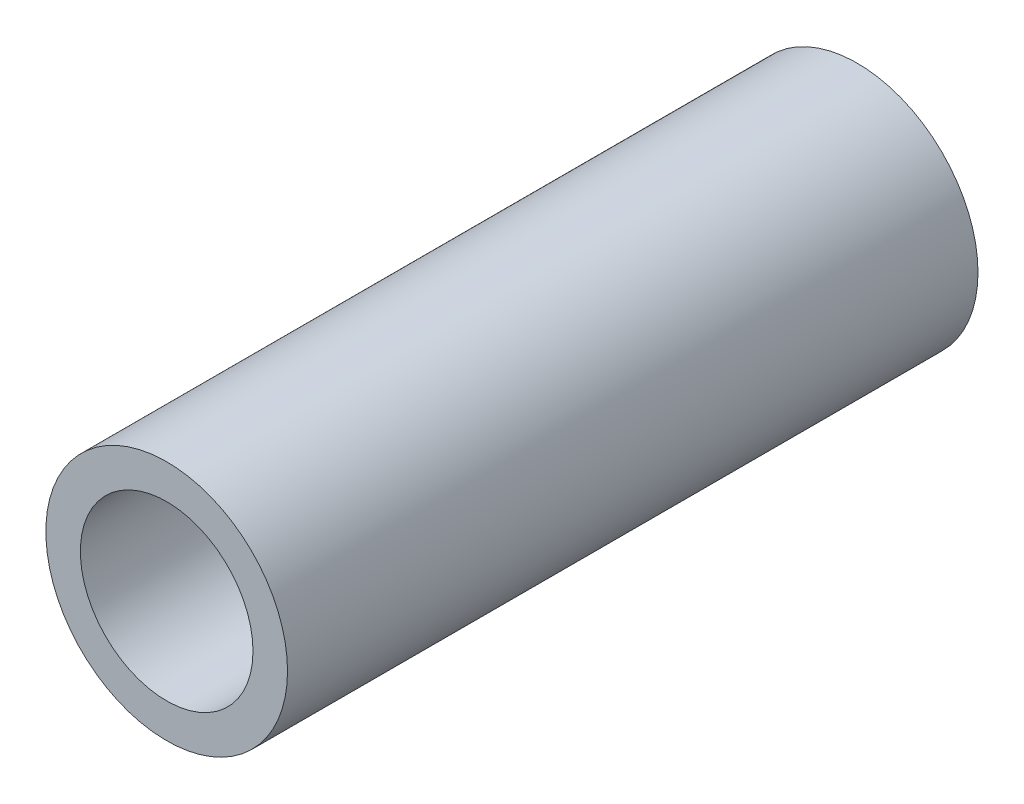
from build123d import *

# Parameters (mm, degrees)
ESBO_O1_R                = 3.5
ESBO_O1_R_2              = 2.5
RESSALTO_EXTRUS_O1_DEPTH = 10


with BuildPart() as part:
    # Esboço1 → Ressalto-extrusão1 (new body, symmetric)
    with BuildSketch(Plane.XY):
        Circle(ESBO_O1_R)
        Circle(ESBO_O1_R_2, mode=Mode.SUBTRACT)
    extrude(amount=RESSALTO_EXTRUS_O1_DEPTH, both=True)


solid = part.part
